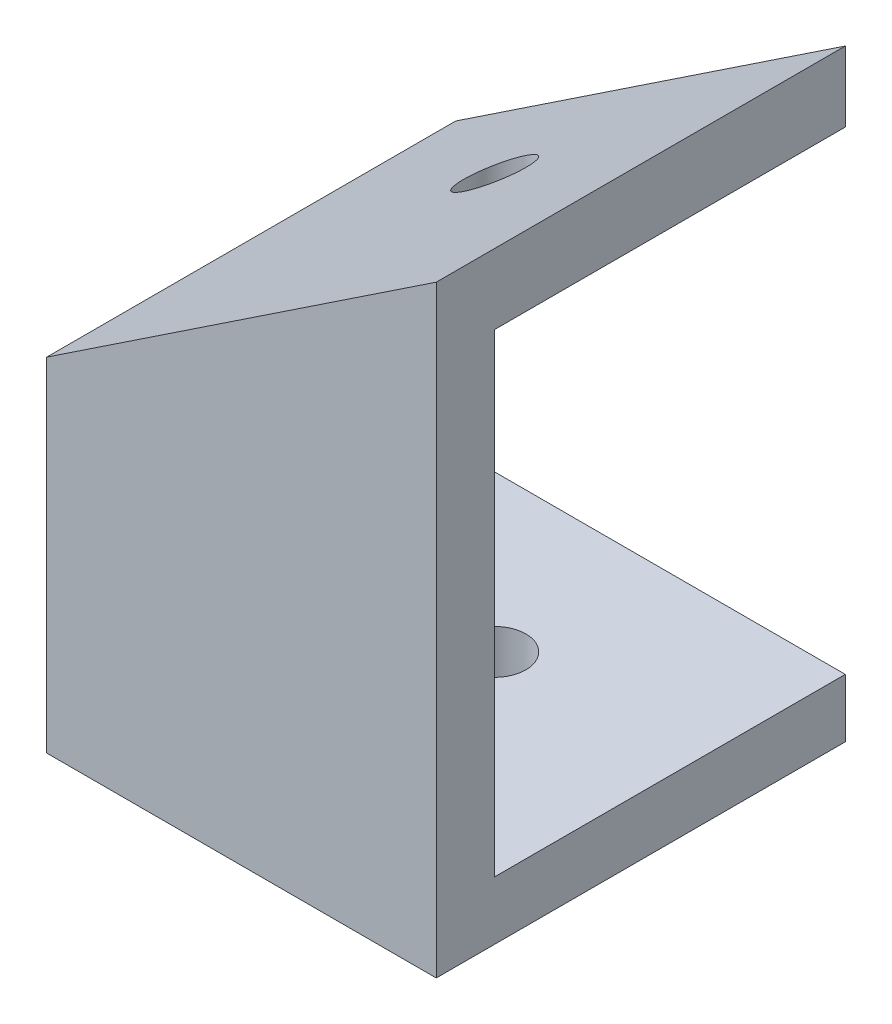
from build123d import *

# Parameters (mm, degrees)
EXTRUDE_1_DEPTH      = 3
SKETCH_2_W           = 20
SKETCH_2_H           = 3
EXTRUDE_2_DEPTH      = 18
EXTRUDE_2_DEPTH_BACK = 3
SKETCH_5_R           = 1.6
CUT_EXTRUDE_1_DEPTH  = 31.938884609
CUT_EXTRUDE_2_DEPTH  = 4
EXTRUDE_3_DEPTH      = 3


with BuildPart() as part:
    # 草图1 → 凸台-拉伸1 (new body)
    with BuildSketch(Plane.XY):
        Polygon((-7.634327041, -2.906141593), (-7.634327041, 8.093858407), (12.365672959, 21.427191741), (12.365672959, -5.906141593), (-7.634327041, -5.906141593), align=None)
    extrude(amount=EXTRUDE_1_DEPTH)

    # 草图2 → 凸台-拉伸2 (add, two sides)
    with BuildSketch(Plane.XY.offset(3)) as extrude_2_sk:
        Polygon((-7.634327041, 8.093858407), (12.365672959, 21.427191741), (12.365672959, 25.032743016), (-7.634327041, 11.699409683), align=None)
        with Locations((2.365672959, -4.406141593)):
            Rectangle(SKETCH_2_W, SKETCH_2_H)
    extrude(amount=EXTRUDE_2_DEPTH)
    extrude(extrude_2_sk.sketch, amount=-EXTRUDE_2_DEPTH_BACK)

    # 草图5 → 切除-拉伸1 (cut, through all)
    with BuildSketch(Plane.XZ.offset(5.906141593)):
        with Locations((2.365672959, 8)):
            Circle(SKETCH_5_R)
    extrude(amount=-CUT_EXTRUDE_1_DEPTH, mode=Mode.SUBTRACT)

    # 草图6 → 切除-拉伸2 (cut, through all)
    with BuildSketch(Plane.XY.offset(3)):
        Polygon((-7.634327041, 8.093858407), (-7.634327041, -2.906141593), (12.365672959, -2.906141593), (12.365672959, 21.427191741), align=None)
    extrude(amount=-CUT_EXTRUDE_2_DEPTH, mode=Mode.SUBTRACT)

    # 草图7 → 凸台-拉伸3 (add)
    with BuildSketch(Plane.XY.offset(21)):
        Polygon((-7.634327041, 11.699409683), (-7.634327041, -5.906141593), (12.365672959, -5.906141593), (12.365672959, 25.032743016), align=None)
    extrude(amount=-EXTRUDE_3_DEPTH)


solid = part.part
